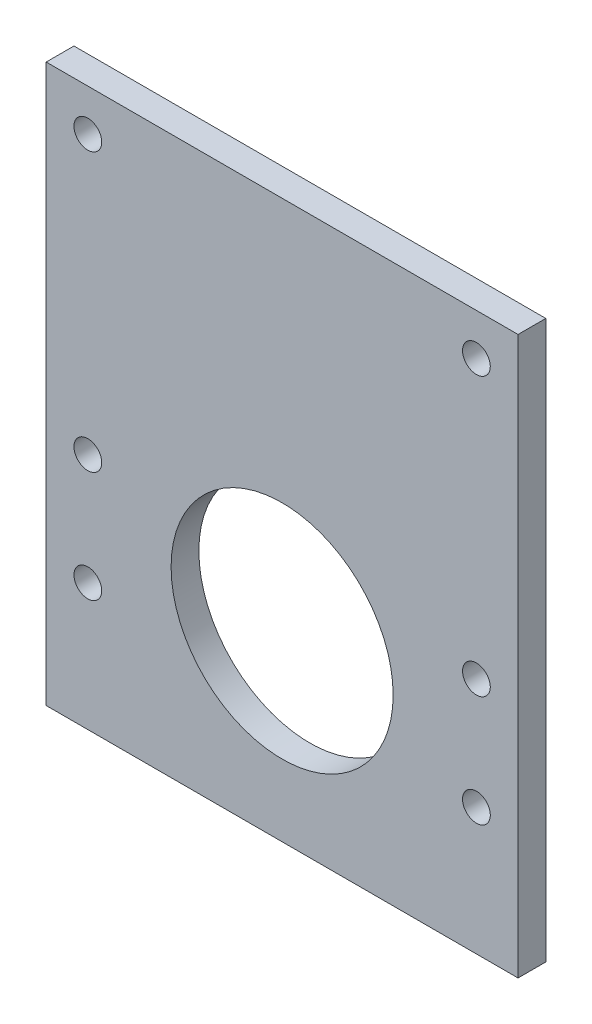
from build123d import *

# Parameters (mm, degrees)
SKETCH1_W           = 107.95
SKETCH1_H           = 127.508
SKETCH1_R           = 25.4
SKETCH1_R_2         = 3.175
BOSS_EXTRUDE1_DEPTH = 6.35


with BuildPart() as part:
    # Sketch1 → Boss-Extrude1 (new body)
    with BuildSketch(Plane.XY):
        with Locations((0, 21.971)):
            Rectangle(SKETCH1_W, SKETCH1_H)
        Circle(SKETCH1_R, mode=Mode.SUBTRACT)
        with Locations((-44.45, 76.2)):
            Circle(SKETCH1_R_2, mode=Mode.SUBTRACT)
        with Locations((44.45, 76.2)):
            Circle(SKETCH1_R_2, mode=Mode.SUBTRACT)
        with Locations((-44.45, 12.7)):
            Circle(SKETCH1_R_2, mode=Mode.SUBTRACT)
        with Locations((-44.45, -12.7)):
            Circle(SKETCH1_R_2, mode=Mode.SUBTRACT)
        with Locations((44.45, -12.7)):
            Circle(SKETCH1_R_2, mode=Mode.SUBTRACT)
        with Locations((44.45, 12.7)):
            Circle(SKETCH1_R_2, mode=Mode.SUBTRACT)
    extrude(amount=BOSS_EXTRUDE1_DEPTH)


solid = part.part
